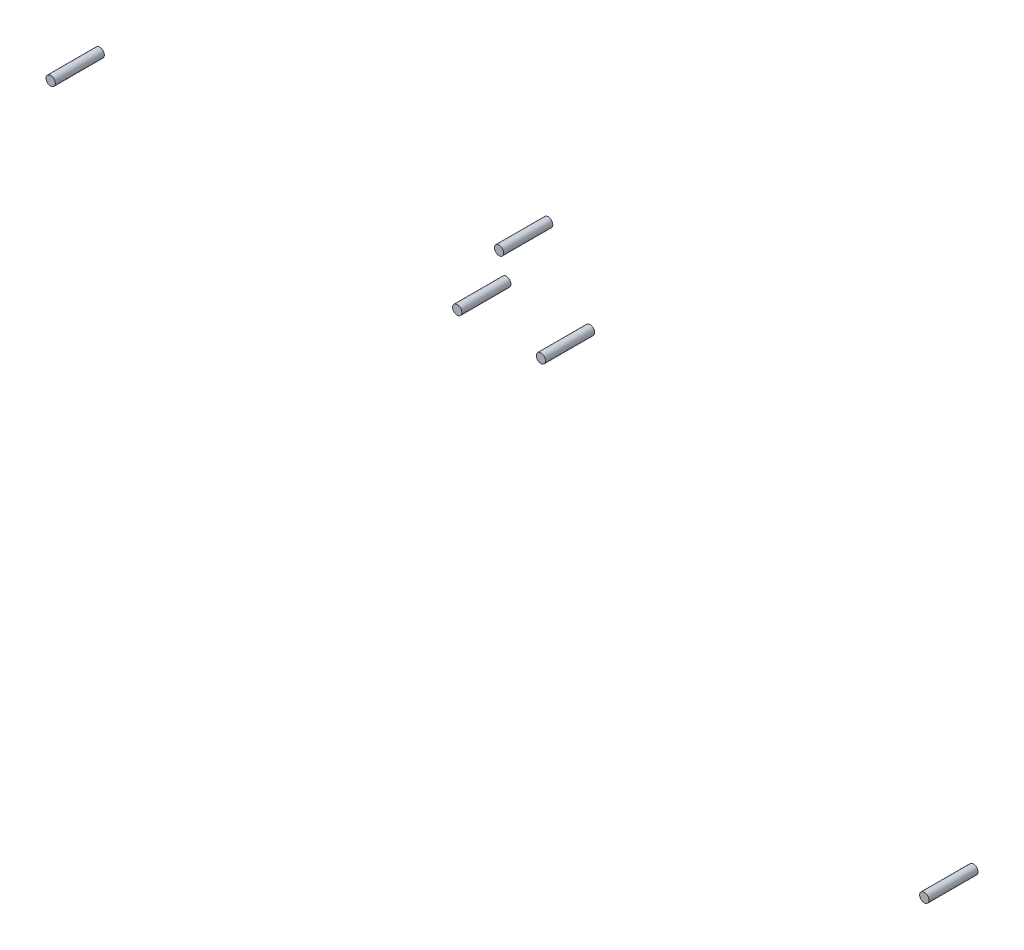
from build123d import *

# Parameters (mm, degrees)
SKETCH2_R             = 0.6
BOSS_EXTRUDE1_DEPTH   = 6.35
BOSS_EXTRUDE1_2_DEPTH = 6.35
BOSS_EXTRUDE1_3_DEPTH = 6.35
BOSS_EXTRUDE1_4_DEPTH = 6.35
BOSS_EXTRUDE1_5_DEPTH = 6.35


with BuildPart() as part:
    # Sketch2 → Boss-Extrude1 (new body)
    with BuildSketch(Plane.XY):
        with Locations((-3.087341226, 50.375)):
            Circle(SKETCH2_R)
    extrude(amount=BOSS_EXTRUDE1_DEPTH)


with BuildPart() as body_2:
    # Sketch2 → Boss-Extrude1 2 (new body)
    with BuildSketch(Plane.XY):
        with Locations((-8.5, 59.75)):
            Circle(SKETCH2_R)
    extrude(amount=BOSS_EXTRUDE1_2_DEPTH)


with BuildPart() as body_3:
    # Sketch2 → Boss-Extrude1 3 (new body)
    with BuildSketch(Plane.XY):
        with Locations((-13.912658774, 50.375)):
            Circle(SKETCH2_R)
    extrude(amount=BOSS_EXTRUDE1_3_DEPTH)


with BuildPart() as body_4:
    # Sketch2 → Boss-Extrude1 4 (new body)
    with BuildSketch(Plane.XY):
        with Locations((46.5, 14.75)):
            Circle(SKETCH2_R)
    extrude(amount=BOSS_EXTRUDE1_4_DEPTH)


with BuildPart() as body_5:
    # Sketch2 → Boss-Extrude1 5 (new body)
    with BuildSketch(Plane.XY):
        with Locations((-66.5, 49.75)):
            Circle(SKETCH2_R)
    extrude(amount=BOSS_EXTRUDE1_5_DEPTH)


solid = Compound([part.part, body_2.part, body_3.part, body_4.part, body_5.part])
